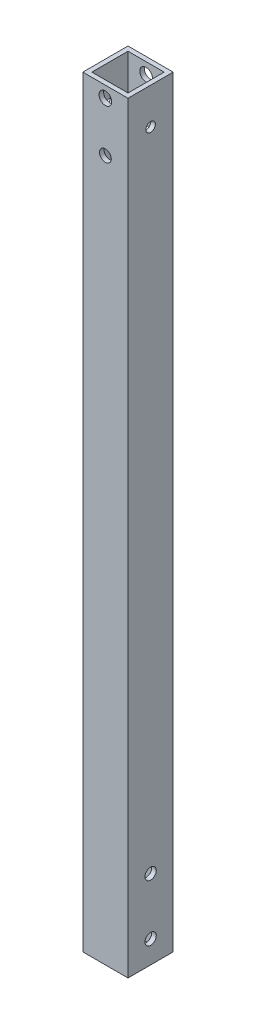
from build123d import *

# Parameters (mm, degrees)
ESBO_O1_W             = 20
ESBO_O1_H             = 20
ESBO_O1_W_2           = 16
ESBO_O1_H_2           = 16
EXTRUS_O_FINA1_DEPTH  = 337
ESBO_O2_R             = 2.5
CORTE_EXTRUS_O1_DEPTH = 21
ESBO_O3_R             = 2.6
ESBO_O3_R_2           = 2.8
CORTE_EXTRUS_O2_DEPTH = 21
ESBO_O4_R             = 2.1
CORTE_EXTRUS_O3_DEPTH = 21


with BuildPart() as part:
    # Esboço1 → Extrusão-Fina1 (new body)
    with BuildSketch(Plane(origin=(0, 0, 0), x_dir=(1, 0, 0), z_dir=(0, 1, 0))):
        with Locations((10, 10)):
            Rectangle(ESBO_O1_W, ESBO_O1_H)
        with Locations((10, 10)):
            Rectangle(ESBO_O1_W_2, ESBO_O1_H_2, mode=Mode.SUBTRACT)
    extrude(amount=EXTRUS_O_FINA1_DEPTH)

    # Esboço2 → Corte-extrusão1 (cut, through all)
    with BuildSketch(Plane.ZY):
        with Locations((-10, 35)):
            Circle(ESBO_O2_R)
        with Locations((-10, 10)):
            Circle(ESBO_O2_R)
    extrude(amount=-CORTE_EXTRUS_O1_DEPTH, mode=Mode.SUBTRACT)

    # Esboço3 → Corte-extrusão2 (cut, through all)
    with BuildSketch(Plane(origin=(0, 0, -20), x_dir=(-1, 0, 0), z_dir=(0, 0, -1))):
        with Locations((-10, 310)):
            Circle(ESBO_O3_R)
        with Locations((-10, 332)):
            Circle(ESBO_O3_R_2)
    extrude(amount=-CORTE_EXTRUS_O2_DEPTH, mode=Mode.SUBTRACT)

    # Esboço4 → Corte-extrusão3 (cut, through all)
    with BuildSketch(Plane(origin=(20, 0, 0), x_dir=(0, 0, -1), z_dir=(1, 0, 0))):
        with Locations((10, 321)):
            Circle(ESBO_O4_R)
    extrude(amount=-CORTE_EXTRUS_O3_DEPTH, mode=Mode.SUBTRACT)


solid = part.part
